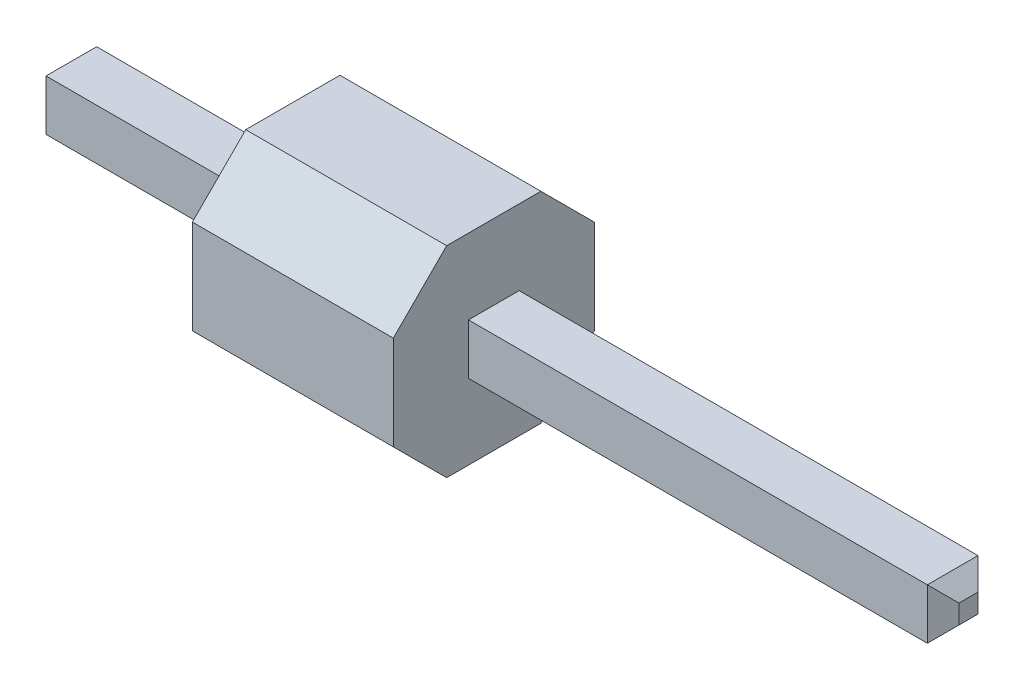
from build123d import *

# Parameters (mm, degrees)
CROQUIS1_W                   = 0.64
CROQUIS1_H                   = 0.64
SALIENTE_EXTRUIR1_DEPTH      = 2.54
CROQUIS3_W                   = 0.64
CROQUIS3_H                   = 0.64
SALIENTE_EXTRUIR2_DEPTH      = 8.54
SALIENTE_EXTRUIR2_DEPTH_BACK = 3
CHAFL_N1_SIZE                = 0.2


with BuildPart() as part:
    # Croquis1 → Saliente-Extruir1 (new body)
    with BuildSketch(Plane(origin=(0, 0, 0), x_dir=(0, 0, -1), z_dir=(1, 0, 0))):
        Polygon((-0.595482683, 1.27), (-1.27, 0.595482683), (-1.27, -0.595482683), (-0.595482683, -1.27), (0.595482683, -1.27), (1.27, -0.595482683), (1.27, 0.595482683), (0.595482683, 1.27), align=None)
        Rectangle(CROQUIS1_W, CROQUIS1_H, mode=Mode.SUBTRACT)
    extrude(amount=SALIENTE_EXTRUIR1_DEPTH)


with BuildPart() as body_2:
    # Croquis3 → Saliente-Extruir2 (new body, two sides)
    with BuildSketch(Plane(origin=(0, 0, 0), x_dir=(0, 0, -1), z_dir=(1, 0, 0))) as saliente_extruir2_sk:
        Rectangle(CROQUIS3_W, CROQUIS3_H)
    extrude(amount=SALIENTE_EXTRUIR2_DEPTH)
    extrude(saliente_extruir2_sk.sketch, amount=-SALIENTE_EXTRUIR2_DEPTH_BACK)

    # Chaflán1
    chafl_n1_edges = [body_2.edges().sort_by_distance(p)[0] for p in [
        (-3, 0, -0.32),
        (8.54, 0, 0.32),
        (8.54, -0.32, 0),
        (-3, 0.32, 0),
        (8.54, 0, -0.32),
        (8.54, 0.32, 0),
        (-3, 0, 0.32),
        (-3, -0.32, 0),
    ]]
    chamfer(chafl_n1_edges, length=CHAFL_N1_SIZE)


solid = Compound([part.part, body_2.part])
